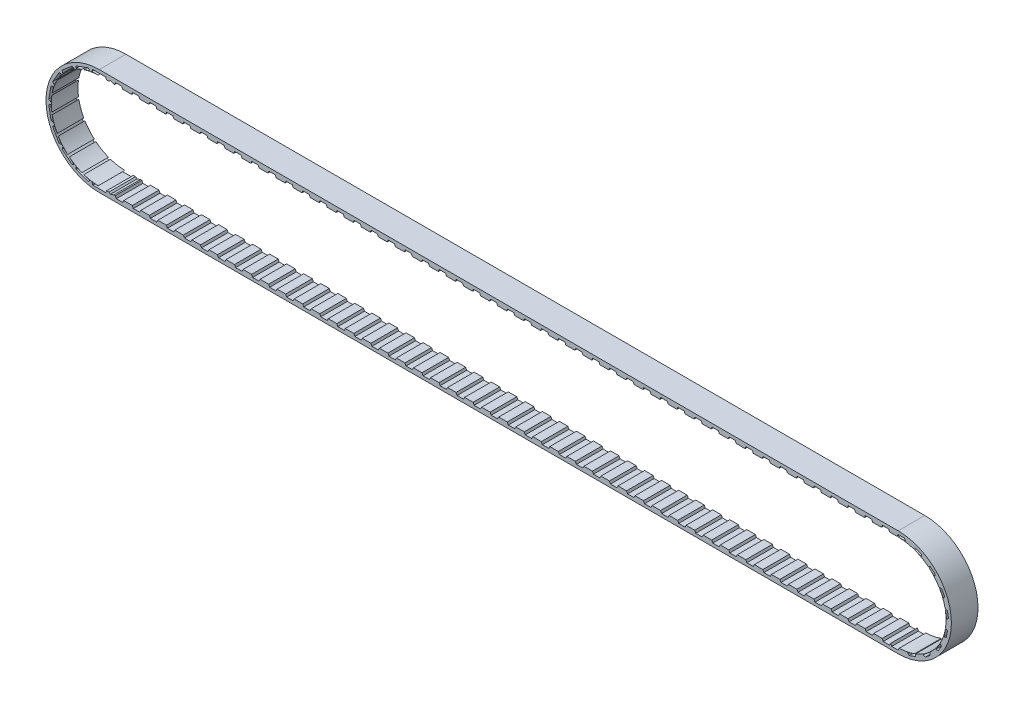
from build123d import *

# Parameters (mm, degrees)
BOSS_EXTRUDE1_DEPTH   = 6.35
CUT_EXTRUDE1_DEPTH    = 8.89
CRVPATTERN1_COUNT     = 48
CRVPATTERN1_PITCH     = 4.064
CIRPATTERN1_COUNT     = 18
MIRROR1_COPY_1_DEPTH  = 8.89
MIRROR1_COPY_2_DEPTH  = 8.89
MIRROR1_COPY_3_DEPTH  = 8.89
MIRROR1_COPY_4_DEPTH  = 8.89
MIRROR1_COPY_5_DEPTH  = 8.89
MIRROR1_COPY_6_DEPTH  = 8.89
MIRROR1_COPY_7_DEPTH  = 8.89
MIRROR1_COPY_8_DEPTH  = 8.89
MIRROR1_COPY_9_DEPTH  = 8.89
MIRROR1_COPY_10_DEPTH = 8.89
MIRROR1_COPY_11_DEPTH = 8.89
MIRROR1_COPY_12_DEPTH = 8.89
MIRROR1_COPY_13_DEPTH = 8.89
MIRROR1_COPY_14_DEPTH = 8.89
MIRROR1_COPY_15_DEPTH = 8.89
MIRROR1_COPY_16_DEPTH = 8.89
MIRROR1_COPY_17_DEPTH = 8.89
MIRROR2_COPY_1_DEPTH  = 8.89
MIRROR2_COPY_2_DEPTH  = 8.89
MIRROR2_COPY_3_DEPTH  = 8.89
MIRROR2_COPY_4_DEPTH  = 8.89
MIRROR2_COPY_5_DEPTH  = 8.89
MIRROR2_COPY_6_DEPTH  = 8.89
MIRROR2_COPY_7_DEPTH  = 8.89
MIRROR2_COPY_8_DEPTH  = 8.89
MIRROR2_COPY_9_DEPTH  = 8.89
MIRROR2_COPY_10_DEPTH = 8.89
MIRROR2_COPY_11_DEPTH = 8.89
MIRROR2_COPY_12_DEPTH = 8.89
MIRROR2_COPY_13_DEPTH = 8.89
MIRROR2_COPY_14_DEPTH = 8.89
MIRROR2_COPY_15_DEPTH = 8.89
MIRROR2_COPY_16_DEPTH = 8.89
MIRROR2_COPY_17_DEPTH = 8.89
CUT_EXTRUDE2_DEPTH    = 8.89
LPATTERN2_COUNT       = 46
LPATTERN2_PITCH       = 4.064


with BuildPart() as part:
    # Sketch1 → Boss-Extrude1 (new body)
    with BuildSketch(Plane.XY):
        with BuildLine():
            Line((-95.25, 12.7), (95.25, 12.7))
            ThreePointArc((95.25, 12.7), (107.95, 0), (95.25, -12.7))
            Line((95.25, -12.7), (-95.25, -12.7))
            ThreePointArc((-95.25, -12.7), (-107.95, 0), (-95.25, 12.7))
        make_face()
        with BuildLine():
            Line((-95.255364061, 11.43), (95.255364061, 11.43))
            ThreePointArc((95.255364061, 11.43), (106.685364061, 0), (95.255364061, -11.43))
            Line((95.255364061, -11.43), (-95.255364061, -11.43))
            ThreePointArc((-95.255364061, -11.43), (-106.685364061, 0), (-95.255364061, 11.43))
        make_face(mode=Mode.SUBTRACT)
    extrude(amount=-BOSS_EXTRUDE1_DEPTH)

    # Sketch2 → Cut-Extrude1 (cut)
    with BuildSketch(Plane.XY):
        with BuildLine():
            Line((-95.255364061, -11.938), (-93.731364061, -11.938))
            Line((-93.731364061, -11.938), (-93.477364061, -11.43))
            Line((-93.477364061, -11.43), (-95.255364061, -11.43))
            ThreePointArc((-95.255364061, -11.43), (-95.382371902, -11.429294336), (-95.509364061, -11.427177429))
            Line((-95.509364061, -11.427177429), (-95.255364061, -11.938))
        make_face()
    cut_extrude1 = extrude(amount=-CUT_EXTRUDE1_DEPTH, mode=Mode.SUBTRACT)

    # CrvPattern1: Cut-Extrude1 ×48, 1 skipped
    with Locations(*[(i * CRVPATTERN1_PITCH, 0, 0) for i in range(1, CRVPATTERN1_COUNT) if i not in (47,)]):
        add(cut_extrude1, mode=Mode.SUBTRACT)

    # CirPattern1: Cut-Extrude1 ×18 about axis
    cirpattern1_axis = Axis((-95.255364061, 0, 0), (0, 0, 1))
    for i in range(1, CIRPATTERN1_COUNT):
        add(cut_extrude1.rotate(cirpattern1_axis, i * 360 / CIRPATTERN1_COUNT), mode=Mode.SUBTRACT)

    # Mirror1: Cut-Extrude1 across plane
    add(cut_extrude1.mirror(Plane(origin=(0, 0, 0), x_dir=(0, 0, 1), z_dir=(1, 0, 0))), mode=Mode.SUBTRACT)

    # Mirror1 copy 1 sketch → Mirror1 copy 1 (cut)
    with BuildSketch(Plane(origin=(5.744601363, 32.579253269, 0), x_dir=(-0.9396926207859084, 0.3420201433256687, 0), z_dir=(0, 0, 1))):
        with BuildLine():
            Line((-95.255364061, 11.938), (-93.731364061, 11.938))
            Line((-93.731364061, 11.938), (-93.477364061, 11.43))
            Line((-93.477364061, 11.43), (-95.255364061, 11.43))
            ThreePointArc((-95.255364061, 11.43), (-95.382371902, 11.429294336), (-95.509364061, 11.427177429))
            Line((-95.509364061, 11.427177429), (-95.255364061, 11.938))
        make_face()
    extrude(amount=-MIRROR1_COPY_1_DEPTH, mode=Mode.SUBTRACT)

    # Mirror1 copy 2 sketch → Mirror1 copy 2 (cut)
    with BuildSketch(Plane(origin=(22.285521745, 61.228967775, 0), x_dir=(-0.766044443118978, 0.6427876096865393, 0), z_dir=(0, 0, 1))):
        with BuildLine():
            Line((-95.255364061, 11.938), (-93.731364061, 11.938))
            Line((-93.731364061, 11.938), (-93.477364061, 11.43))
            Line((-93.477364061, 11.43), (-95.255364061, 11.43))
            ThreePointArc((-95.255364061, 11.43), (-95.382371902, 11.429294336), (-95.509364061, 11.427177429))
            Line((-95.509364061, 11.427177429), (-95.255364061, 11.938))
        make_face()
    extrude(amount=-MIRROR1_COPY_2_DEPTH, mode=Mode.SUBTRACT)

    # Mirror1 copy 3 sketch → Mirror1 copy 3 (cut)
    with BuildSketch(Plane(origin=(47.627682031, 82.493565124, 0), x_dir=(-0.5000000000000001, 0.8660254037844386, 0), z_dir=(0, 0, 1))):
        with BuildLine():
            Line((-95.255364061, 11.938), (-93.731364061, 11.938))
            Line((-93.731364061, 11.938), (-93.477364061, 11.43))
            Line((-93.477364061, 11.43), (-95.255364061, 11.43))
            ThreePointArc((-95.255364061, 11.43), (-95.382371902, 11.429294336), (-95.509364061, 11.427177429))
            Line((-95.509364061, 11.427177429), (-95.255364061, 11.938))
        make_face()
    extrude(amount=-MIRROR1_COPY_3_DEPTH, mode=Mode.SUBTRACT)

    # Mirror1 copy 4 sketch → Mirror1 copy 4 (cut)
    with BuildSketch(Plane(origin=(78.714443679, 93.808221043, 0), x_dir=(-0.17364817766693041, 0.984807753012208, 0), z_dir=(0, 0, 1))):
        with BuildLine():
            Line((-95.255364061, 11.938), (-93.731364061, 11.938))
            Line((-93.731364061, 11.938), (-93.477364061, 11.43))
            Line((-93.477364061, 11.43), (-95.255364061, 11.43))
            ThreePointArc((-95.255364061, 11.43), (-95.382371902, 11.429294336), (-95.509364061, 11.427177429))
            Line((-95.509364061, 11.427177429), (-95.255364061, 11.938))
        make_face()
    extrude(amount=-MIRROR1_COPY_4_DEPTH, mode=Mode.SUBTRACT)

    # Mirror1 copy 5 sketch → Mirror1 copy 5 (cut)
    with BuildSketch(Plane(origin=(111.796284443, 93.808221043, 0), x_dir=(0.1736481776669303, 0.984807753012208, 0), z_dir=(0, 0, 1))):
        with BuildLine():
            Line((-95.255364061, 11.938), (-93.731364061, 11.938))
            Line((-93.731364061, 11.938), (-93.477364061, 11.43))
            Line((-93.477364061, 11.43), (-95.255364061, 11.43))
            ThreePointArc((-95.255364061, 11.43), (-95.382371902, 11.429294336), (-95.509364061, 11.427177429))
            Line((-95.509364061, 11.427177429), (-95.255364061, 11.938))
        make_face()
    extrude(amount=-MIRROR1_COPY_5_DEPTH, mode=Mode.SUBTRACT)

    # Mirror1 copy 6 sketch → Mirror1 copy 6 (cut)
    with BuildSketch(Plane(origin=(142.883046092, 82.493565124, 0), x_dir=(0.4999999999999998, 0.8660254037844387, 0), z_dir=(0, 0, 1))):
        with BuildLine():
            Line((-95.255364061, 11.938), (-93.731364061, 11.938))
            Line((-93.731364061, 11.938), (-93.477364061, 11.43))
            Line((-93.477364061, 11.43), (-95.255364061, 11.43))
            ThreePointArc((-95.255364061, 11.43), (-95.382371902, 11.429294336), (-95.509364061, 11.427177429))
            Line((-95.509364061, 11.427177429), (-95.255364061, 11.938))
        make_face()
    extrude(amount=-MIRROR1_COPY_6_DEPTH, mode=Mode.SUBTRACT)

    # Mirror1 copy 7 sketch → Mirror1 copy 7 (cut)
    with BuildSketch(Plane(origin=(168.225206377, 61.228967775, 0), x_dir=(0.7660444431189779, 0.6427876096865395, 0), z_dir=(0, 0, 1))):
        with BuildLine():
            Line((-95.255364061, 11.938), (-93.731364061, 11.938))
            Line((-93.731364061, 11.938), (-93.477364061, 11.43))
            Line((-93.477364061, 11.43), (-95.255364061, 11.43))
            ThreePointArc((-95.255364061, 11.43), (-95.382371902, 11.429294336), (-95.509364061, 11.427177429))
            Line((-95.509364061, 11.427177429), (-95.255364061, 11.938))
        make_face()
    extrude(amount=-MIRROR1_COPY_7_DEPTH, mode=Mode.SUBTRACT)

    # Mirror1 copy 8 sketch → Mirror1 copy 8 (cut)
    with BuildSketch(Plane(origin=(184.766126759, 32.579253269, 0), x_dir=(0.9396926207859083, 0.3420201433256689, 0), z_dir=(0, 0, 1))):
        with BuildLine():
            Line((-95.255364061, 11.938), (-93.731364061, 11.938))
            Line((-93.731364061, 11.938), (-93.477364061, 11.43))
            Line((-93.477364061, 11.43), (-95.255364061, 11.43))
            ThreePointArc((-95.255364061, 11.43), (-95.382371902, 11.429294336), (-95.509364061, 11.427177429))
            Line((-95.509364061, 11.427177429), (-95.255364061, 11.938))
        make_face()
    extrude(amount=-MIRROR1_COPY_8_DEPTH, mode=Mode.SUBTRACT)

    # Mirror1 copy 9 sketch → Mirror1 copy 9 (cut)
    with BuildSketch(Plane(origin=(190.510728122, 0, 0), x_dir=(1, 0, 0), z_dir=(0, 0, 1))):
        with BuildLine():
            Line((-95.255364061, 11.938), (-93.731364061, 11.938))
            Line((-93.731364061, 11.938), (-93.477364061, 11.43))
            Line((-93.477364061, 11.43), (-95.255364061, 11.43))
            ThreePointArc((-95.255364061, 11.43), (-95.382371902, 11.429294336), (-95.509364061, 11.427177429))
            Line((-95.509364061, 11.427177429), (-95.255364061, 11.938))
        make_face()
    extrude(amount=-MIRROR1_COPY_9_DEPTH, mode=Mode.SUBTRACT)

    # Mirror1 copy 10 sketch → Mirror1 copy 10 (cut)
    with BuildSketch(Plane(origin=(184.766126759, -32.579253269, 0), x_dir=(0.9396926207859084, -0.34202014332566866, 0), z_dir=(0, 0, 1))):
        with BuildLine():
            Line((-95.255364061, 11.938), (-93.731364061, 11.938))
            Line((-93.731364061, 11.938), (-93.477364061, 11.43))
            Line((-93.477364061, 11.43), (-95.255364061, 11.43))
            ThreePointArc((-95.255364061, 11.43), (-95.382371902, 11.429294336), (-95.509364061, 11.427177429))
            Line((-95.509364061, 11.427177429), (-95.255364061, 11.938))
        make_face()
    extrude(amount=-MIRROR1_COPY_10_DEPTH, mode=Mode.SUBTRACT)

    # Mirror1 copy 11 sketch → Mirror1 copy 11 (cut)
    with BuildSketch(Plane(origin=(168.225206377, -61.228967775, 0), x_dir=(0.766044443118978, -0.6427876096865393, 0), z_dir=(0, 0, 1))):
        with BuildLine():
            Line((-95.255364061, 11.938), (-93.731364061, 11.938))
            Line((-93.731364061, 11.938), (-93.477364061, 11.43))
            Line((-93.477364061, 11.43), (-95.255364061, 11.43))
            ThreePointArc((-95.255364061, 11.43), (-95.382371902, 11.429294336), (-95.509364061, 11.427177429))
            Line((-95.509364061, 11.427177429), (-95.255364061, 11.938))
        make_face()
    extrude(amount=-MIRROR1_COPY_11_DEPTH, mode=Mode.SUBTRACT)

    # Mirror1 copy 12 sketch → Mirror1 copy 12 (cut)
    with BuildSketch(Plane(origin=(142.883046092, -82.493565124, 0), x_dir=(0.5000000000000004, -0.8660254037844384, 0), z_dir=(0, 0, 1))):
        with BuildLine():
            Line((-95.255364061, 11.938), (-93.731364061, 11.938))
            Line((-93.731364061, 11.938), (-93.477364061, 11.43))
            Line((-93.477364061, 11.43), (-95.255364061, 11.43))
            ThreePointArc((-95.255364061, 11.43), (-95.382371902, 11.429294336), (-95.509364061, 11.427177429))
            Line((-95.509364061, 11.427177429), (-95.255364061, 11.938))
        make_face()
    extrude(amount=-MIRROR1_COPY_12_DEPTH, mode=Mode.SUBTRACT)

    # Mirror1 copy 13 sketch → Mirror1 copy 13 (cut)
    with BuildSketch(Plane(origin=(111.796284443, -93.808221043, 0), x_dir=(0.17364817766693033, -0.984807753012208, 0), z_dir=(0, 0, 1))):
        with BuildLine():
            Line((-95.255364061, 11.938), (-93.731364061, 11.938))
            Line((-93.731364061, 11.938), (-93.477364061, 11.43))
            Line((-93.477364061, 11.43), (-95.255364061, 11.43))
            ThreePointArc((-95.255364061, 11.43), (-95.382371902, 11.429294336), (-95.509364061, 11.427177429))
            Line((-95.509364061, 11.427177429), (-95.255364061, 11.938))
        make_face()
    extrude(amount=-MIRROR1_COPY_13_DEPTH, mode=Mode.SUBTRACT)

    # Mirror1 copy 14 sketch → Mirror1 copy 14 (cut)
    with BuildSketch(Plane(origin=(78.714443679, -93.808221043, 0), x_dir=(-0.17364817766692997, -0.9848077530122081, 0), z_dir=(0, 0, 1))):
        with BuildLine():
            Line((-95.255364061, 11.938), (-93.731364061, 11.938))
            Line((-93.731364061, 11.938), (-93.477364061, 11.43))
            Line((-93.477364061, 11.43), (-95.255364061, 11.43))
            ThreePointArc((-95.255364061, 11.43), (-95.382371902, 11.429294336), (-95.509364061, 11.427177429))
            Line((-95.509364061, 11.427177429), (-95.255364061, 11.938))
        make_face()
    extrude(amount=-MIRROR1_COPY_14_DEPTH, mode=Mode.SUBTRACT)

    # Mirror1 copy 15 sketch → Mirror1 copy 15 (cut)
    with BuildSketch(Plane(origin=(47.627682031, -82.493565124, 0), x_dir=(-0.5000000000000001, -0.8660254037844386, 0), z_dir=(0, 0, 1))):
        with BuildLine():
            Line((-95.255364061, 11.938), (-93.731364061, 11.938))
            Line((-93.731364061, 11.938), (-93.477364061, 11.43))
            Line((-93.477364061, 11.43), (-95.255364061, 11.43))
            ThreePointArc((-95.255364061, 11.43), (-95.382371902, 11.429294336), (-95.509364061, 11.427177429))
            Line((-95.509364061, 11.427177429), (-95.255364061, 11.938))
        make_face()
    extrude(amount=-MIRROR1_COPY_15_DEPTH, mode=Mode.SUBTRACT)

    # Mirror1 copy 16 sketch → Mirror1 copy 16 (cut)
    with BuildSketch(Plane(origin=(22.285521745, -61.228967775, 0), x_dir=(-0.7660444431189778, -0.6427876096865396, 0), z_dir=(0, 0, 1))):
        with BuildLine():
            Line((-95.255364061, 11.938), (-93.731364061, 11.938))
            Line((-93.731364061, 11.938), (-93.477364061, 11.43))
            Line((-93.477364061, 11.43), (-95.255364061, 11.43))
            ThreePointArc((-95.255364061, 11.43), (-95.382371902, 11.429294336), (-95.509364061, 11.427177429))
            Line((-95.509364061, 11.427177429), (-95.255364061, 11.938))
        make_face()
    extrude(amount=-MIRROR1_COPY_16_DEPTH, mode=Mode.SUBTRACT)

    # Mirror1 copy 17 sketch → Mirror1 copy 17 (cut)
    with BuildSketch(Plane(origin=(5.744601363, -32.579253269, 0), x_dir=(-0.9396926207859084, -0.3420201433256686, 0), z_dir=(0, 0, 1))):
        with BuildLine():
            Line((-95.255364061, 11.938), (-93.731364061, 11.938))
            Line((-93.731364061, 11.938), (-93.477364061, 11.43))
            Line((-93.477364061, 11.43), (-95.255364061, 11.43))
            ThreePointArc((-95.255364061, 11.43), (-95.382371902, 11.429294336), (-95.509364061, 11.427177429))
            Line((-95.509364061, 11.427177429), (-95.255364061, 11.938))
        make_face()
    extrude(amount=-MIRROR1_COPY_17_DEPTH, mode=Mode.SUBTRACT)

    # Mirror2: Cut-Extrude1 across plane
    add(cut_extrude1.mirror(Plane.ZX), mode=Mode.SUBTRACT)

    # Mirror2 copy 1 sketch → Mirror2 copy 1 (cut)
    with BuildSketch(Plane(origin=(-5.744601363, -32.579253269, 0), x_dir=(0.9396926207859084, -0.3420201433256687, 0), z_dir=(0, 0, 1))):
        with BuildLine():
            Line((-95.255364061, 11.938), (-93.731364061, 11.938))
            Line((-93.731364061, 11.938), (-93.477364061, 11.43))
            Line((-93.477364061, 11.43), (-95.255364061, 11.43))
            ThreePointArc((-95.255364061, 11.43), (-95.382371902, 11.429294336), (-95.509364061, 11.427177429))
            Line((-95.509364061, 11.427177429), (-95.255364061, 11.938))
        make_face()
    extrude(amount=-MIRROR2_COPY_1_DEPTH, mode=Mode.SUBTRACT)

    # Mirror2 copy 2 sketch → Mirror2 copy 2 (cut)
    with BuildSketch(Plane(origin=(-22.285521745, -61.228967775, 0), x_dir=(0.766044443118978, -0.6427876096865393, 0), z_dir=(0, 0, 1))):
        with BuildLine():
            Line((-95.255364061, 11.938), (-93.731364061, 11.938))
            Line((-93.731364061, 11.938), (-93.477364061, 11.43))
            Line((-93.477364061, 11.43), (-95.255364061, 11.43))
            ThreePointArc((-95.255364061, 11.43), (-95.382371902, 11.429294336), (-95.509364061, 11.427177429))
            Line((-95.509364061, 11.427177429), (-95.255364061, 11.938))
        make_face()
    extrude(amount=-MIRROR2_COPY_2_DEPTH, mode=Mode.SUBTRACT)

    # Mirror2 copy 3 sketch → Mirror2 copy 3 (cut)
    with BuildSketch(Plane(origin=(-47.627682031, -82.493565124, 0), x_dir=(0.5000000000000001, -0.8660254037844386, 0), z_dir=(0, 0, 1))):
        with BuildLine():
            Line((-95.255364061, 11.938), (-93.731364061, 11.938))
            Line((-93.731364061, 11.938), (-93.477364061, 11.43))
            Line((-93.477364061, 11.43), (-95.255364061, 11.43))
            ThreePointArc((-95.255364061, 11.43), (-95.382371902, 11.429294336), (-95.509364061, 11.427177429))
            Line((-95.509364061, 11.427177429), (-95.255364061, 11.938))
        make_face()
    extrude(amount=-MIRROR2_COPY_3_DEPTH, mode=Mode.SUBTRACT)

    # Mirror2 copy 4 sketch → Mirror2 copy 4 (cut)
    with BuildSketch(Plane(origin=(-78.714443679, -93.808221043, 0), x_dir=(0.17364817766693041, -0.984807753012208, 0), z_dir=(0, 0, 1))):
        with BuildLine():
            Line((-95.255364061, 11.938), (-93.731364061, 11.938))
            Line((-93.731364061, 11.938), (-93.477364061, 11.43))
            Line((-93.477364061, 11.43), (-95.255364061, 11.43))
            ThreePointArc((-95.255364061, 11.43), (-95.382371902, 11.429294336), (-95.509364061, 11.427177429))
            Line((-95.509364061, 11.427177429), (-95.255364061, 11.938))
        make_face()
    extrude(amount=-MIRROR2_COPY_4_DEPTH, mode=Mode.SUBTRACT)

    # Mirror2 copy 5 sketch → Mirror2 copy 5 (cut)
    with BuildSketch(Plane(origin=(-111.796284443, -93.808221043, 0), x_dir=(-0.1736481776669303, -0.984807753012208, 0), z_dir=(0, 0, 1))):
        with BuildLine():
            Line((-95.255364061, 11.938), (-93.731364061, 11.938))
            Line((-93.731364061, 11.938), (-93.477364061, 11.43))
            Line((-93.477364061, 11.43), (-95.255364061, 11.43))
            ThreePointArc((-95.255364061, 11.43), (-95.382371902, 11.429294336), (-95.509364061, 11.427177429))
            Line((-95.509364061, 11.427177429), (-95.255364061, 11.938))
        make_face()
    extrude(amount=-MIRROR2_COPY_5_DEPTH, mode=Mode.SUBTRACT)

    # Mirror2 copy 6 sketch → Mirror2 copy 6 (cut)
    with BuildSketch(Plane(origin=(-142.883046092, -82.493565124, 0), x_dir=(-0.4999999999999998, -0.8660254037844387, 0), z_dir=(0, 0, 1))):
        with BuildLine():
            Line((-95.255364061, 11.938), (-93.731364061, 11.938))
            Line((-93.731364061, 11.938), (-93.477364061, 11.43))
            Line((-93.477364061, 11.43), (-95.255364061, 11.43))
            ThreePointArc((-95.255364061, 11.43), (-95.382371902, 11.429294336), (-95.509364061, 11.427177429))
            Line((-95.509364061, 11.427177429), (-95.255364061, 11.938))
        make_face()
    extrude(amount=-MIRROR2_COPY_6_DEPTH, mode=Mode.SUBTRACT)

    # Mirror2 copy 7 sketch → Mirror2 copy 7 (cut)
    with BuildSketch(Plane(origin=(-168.225206377, -61.228967775, 0), x_dir=(-0.7660444431189779, -0.6427876096865395, 0), z_dir=(0, 0, 1))):
        with BuildLine():
            Line((-95.255364061, 11.938), (-93.731364061, 11.938))
            Line((-93.731364061, 11.938), (-93.477364061, 11.43))
            Line((-93.477364061, 11.43), (-95.255364061, 11.43))
            ThreePointArc((-95.255364061, 11.43), (-95.382371902, 11.429294336), (-95.509364061, 11.427177429))
            Line((-95.509364061, 11.427177429), (-95.255364061, 11.938))
        make_face()
    extrude(amount=-MIRROR2_COPY_7_DEPTH, mode=Mode.SUBTRACT)

    # Mirror2 copy 8 sketch → Mirror2 copy 8 (cut)
    with BuildSketch(Plane(origin=(-184.766126759, -32.579253269, 0), x_dir=(-0.9396926207859083, -0.3420201433256689, 0), z_dir=(0, 0, 1))):
        with BuildLine():
            Line((-95.255364061, 11.938), (-93.731364061, 11.938))
            Line((-93.731364061, 11.938), (-93.477364061, 11.43))
            Line((-93.477364061, 11.43), (-95.255364061, 11.43))
            ThreePointArc((-95.255364061, 11.43), (-95.382371902, 11.429294336), (-95.509364061, 11.427177429))
            Line((-95.509364061, 11.427177429), (-95.255364061, 11.938))
        make_face()
    extrude(amount=-MIRROR2_COPY_8_DEPTH, mode=Mode.SUBTRACT)

    # Mirror2 copy 9 sketch → Mirror2 copy 9 (cut)
    with BuildSketch(Plane(origin=(-190.510728122, 0, 0), x_dir=(-1, 0, 0), z_dir=(0, 0, 1))):
        with BuildLine():
            Line((-95.255364061, 11.938), (-93.731364061, 11.938))
            Line((-93.731364061, 11.938), (-93.477364061, 11.43))
            Line((-93.477364061, 11.43), (-95.255364061, 11.43))
            ThreePointArc((-95.255364061, 11.43), (-95.382371902, 11.429294336), (-95.509364061, 11.427177429))
            Line((-95.509364061, 11.427177429), (-95.255364061, 11.938))
        make_face()
    extrude(amount=-MIRROR2_COPY_9_DEPTH, mode=Mode.SUBTRACT)

    # Mirror2 copy 10 sketch → Mirror2 copy 10 (cut)
    with BuildSketch(Plane(origin=(-184.766126759, 32.579253269, 0), x_dir=(-0.9396926207859084, 0.34202014332566866, 0), z_dir=(0, 0, 1))):
        with BuildLine():
            Line((-95.255364061, 11.938), (-93.731364061, 11.938))
            Line((-93.731364061, 11.938), (-93.477364061, 11.43))
            Line((-93.477364061, 11.43), (-95.255364061, 11.43))
            ThreePointArc((-95.255364061, 11.43), (-95.382371902, 11.429294336), (-95.509364061, 11.427177429))
            Line((-95.509364061, 11.427177429), (-95.255364061, 11.938))
        make_face()
    extrude(amount=-MIRROR2_COPY_10_DEPTH, mode=Mode.SUBTRACT)

    # Mirror2 copy 11 sketch → Mirror2 copy 11 (cut)
    with BuildSketch(Plane(origin=(-168.225206377, 61.228967775, 0), x_dir=(-0.766044443118978, 0.6427876096865393, 0), z_dir=(0, 0, 1))):
        with BuildLine():
            Line((-95.255364061, 11.938), (-93.731364061, 11.938))
            Line((-93.731364061, 11.938), (-93.477364061, 11.43))
            Line((-93.477364061, 11.43), (-95.255364061, 11.43))
            ThreePointArc((-95.255364061, 11.43), (-95.382371902, 11.429294336), (-95.509364061, 11.427177429))
            Line((-95.509364061, 11.427177429), (-95.255364061, 11.938))
        make_face()
    extrude(amount=-MIRROR2_COPY_11_DEPTH, mode=Mode.SUBTRACT)

    # Mirror2 copy 12 sketch → Mirror2 copy 12 (cut)
    with BuildSketch(Plane(origin=(-142.883046092, 82.493565124, 0), x_dir=(-0.5000000000000004, 0.8660254037844384, 0), z_dir=(0, 0, 1))):
        with BuildLine():
            Line((-95.255364061, 11.938), (-93.731364061, 11.938))
            Line((-93.731364061, 11.938), (-93.477364061, 11.43))
            Line((-93.477364061, 11.43), (-95.255364061, 11.43))
            ThreePointArc((-95.255364061, 11.43), (-95.382371902, 11.429294336), (-95.509364061, 11.427177429))
            Line((-95.509364061, 11.427177429), (-95.255364061, 11.938))
        make_face()
    extrude(amount=-MIRROR2_COPY_12_DEPTH, mode=Mode.SUBTRACT)

    # Mirror2 copy 13 sketch → Mirror2 copy 13 (cut)
    with BuildSketch(Plane(origin=(-111.796284443, 93.808221043, 0), x_dir=(-0.17364817766693033, 0.984807753012208, 0), z_dir=(0, 0, 1))):
        with BuildLine():
            Line((-95.255364061, 11.938), (-93.731364061, 11.938))
            Line((-93.731364061, 11.938), (-93.477364061, 11.43))
            Line((-93.477364061, 11.43), (-95.255364061, 11.43))
            ThreePointArc((-95.255364061, 11.43), (-95.382371902, 11.429294336), (-95.509364061, 11.427177429))
            Line((-95.509364061, 11.427177429), (-95.255364061, 11.938))
        make_face()
    extrude(amount=-MIRROR2_COPY_13_DEPTH, mode=Mode.SUBTRACT)

    # Mirror2 copy 14 sketch → Mirror2 copy 14 (cut)
    with BuildSketch(Plane(origin=(-78.714443679, 93.808221043, 0), x_dir=(0.17364817766692997, 0.9848077530122081, 0), z_dir=(0, 0, 1))):
        with BuildLine():
            Line((-95.255364061, 11.938), (-93.731364061, 11.938))
            Line((-93.731364061, 11.938), (-93.477364061, 11.43))
            Line((-93.477364061, 11.43), (-95.255364061, 11.43))
            ThreePointArc((-95.255364061, 11.43), (-95.382371902, 11.429294336), (-95.509364061, 11.427177429))
            Line((-95.509364061, 11.427177429), (-95.255364061, 11.938))
        make_face()
    extrude(amount=-MIRROR2_COPY_14_DEPTH, mode=Mode.SUBTRACT)

    # Mirror2 copy 15 sketch → Mirror2 copy 15 (cut)
    with BuildSketch(Plane(origin=(-47.627682031, 82.493565124, 0), x_dir=(0.5000000000000001, 0.8660254037844386, 0), z_dir=(0, 0, 1))):
        with BuildLine():
            Line((-95.255364061, 11.938), (-93.731364061, 11.938))
            Line((-93.731364061, 11.938), (-93.477364061, 11.43))
            Line((-93.477364061, 11.43), (-95.255364061, 11.43))
            ThreePointArc((-95.255364061, 11.43), (-95.382371902, 11.429294336), (-95.509364061, 11.427177429))
            Line((-95.509364061, 11.427177429), (-95.255364061, 11.938))
        make_face()
    extrude(amount=-MIRROR2_COPY_15_DEPTH, mode=Mode.SUBTRACT)

    # Mirror2 copy 16 sketch → Mirror2 copy 16 (cut)
    with BuildSketch(Plane(origin=(-22.285521745, 61.228967775, 0), x_dir=(0.7660444431189778, 0.6427876096865396, 0), z_dir=(0, 0, 1))):
        with BuildLine():
            Line((-95.255364061, 11.938), (-93.731364061, 11.938))
            Line((-93.731364061, 11.938), (-93.477364061, 11.43))
            Line((-93.477364061, 11.43), (-95.255364061, 11.43))
            ThreePointArc((-95.255364061, 11.43), (-95.382371902, 11.429294336), (-95.509364061, 11.427177429))
            Line((-95.509364061, 11.427177429), (-95.255364061, 11.938))
        make_face()
    extrude(amount=-MIRROR2_COPY_16_DEPTH, mode=Mode.SUBTRACT)

    # Mirror2 copy 17 sketch → Mirror2 copy 17 (cut)
    with BuildSketch(Plane(origin=(-5.744601363, 32.579253269, 0), x_dir=(0.9396926207859084, 0.3420201433256686, 0), z_dir=(0, 0, 1))):
        with BuildLine():
            Line((-95.255364061, 11.938), (-93.731364061, 11.938))
            Line((-93.731364061, 11.938), (-93.477364061, 11.43))
            Line((-93.477364061, 11.43), (-95.255364061, 11.43))
            ThreePointArc((-95.255364061, 11.43), (-95.382371902, 11.429294336), (-95.509364061, 11.427177429))
            Line((-95.509364061, 11.427177429), (-95.255364061, 11.938))
        make_face()
    extrude(amount=-MIRROR2_COPY_17_DEPTH, mode=Mode.SUBTRACT)

    # Sketch3 → Cut-Extrude2 (cut)
    with BuildSketch(Plane.XY):
        Polygon((-91.645907376, 11.303), (-89.613907376, 11.303), (-89.867907376, 11.938), (-91.391907376, 11.938), align=None)
    cut_extrude2 = extrude(amount=-CUT_EXTRUDE2_DEPTH, mode=Mode.SUBTRACT)

    # LPattern2: Cut-Extrude2 ×46
    with Locations(*[(i * LPATTERN2_PITCH, 0, 0) for i in range(1, LPATTERN2_COUNT)]):
        add(cut_extrude2, mode=Mode.SUBTRACT)


solid = part.part
